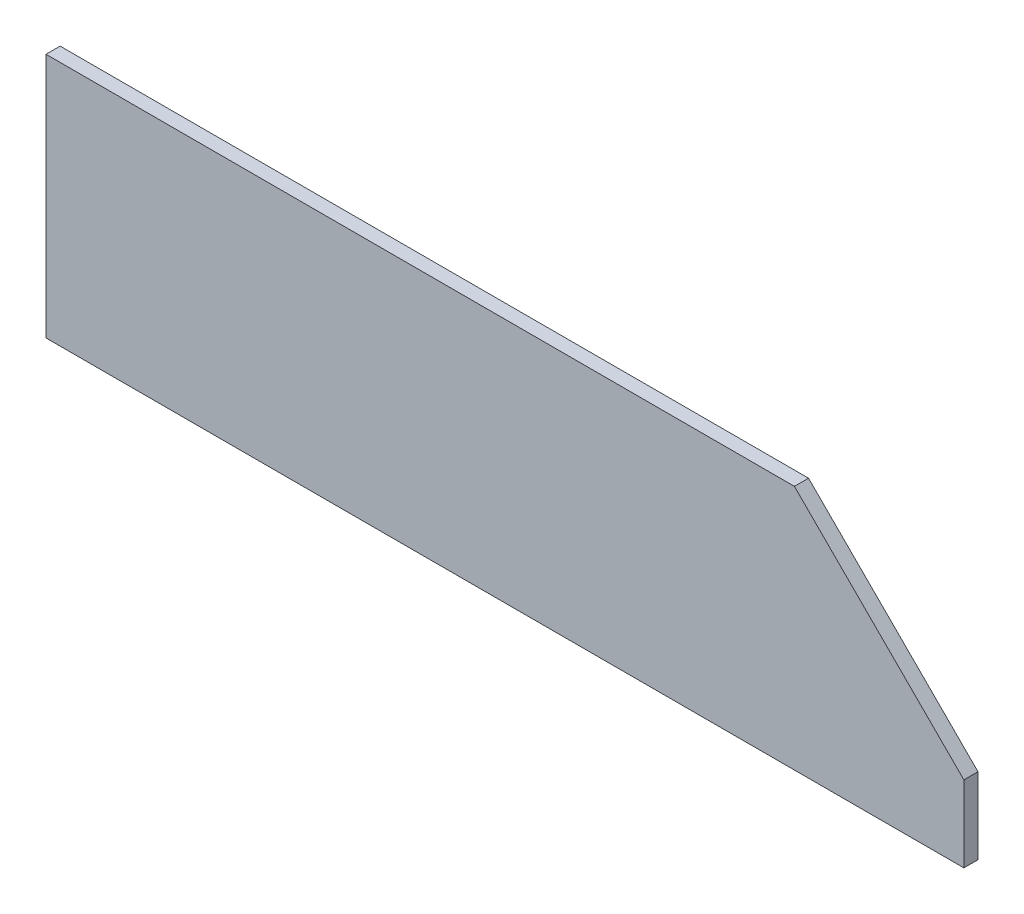
from build123d import *

# Parameters (mm, degrees)
SKETCH1_W           = 325
SKETCH1_H           = 5
BOSS_EXTRUDE1_DEPTH = 87
CHAMFER1_SIZE       = 60


with BuildPart() as part:
    # Sketch1 → Boss-Extrude1 (new body)
    with BuildSketch(Plane(origin=(0, 0, 0), x_dir=(1, 0, 0), z_dir=(0, 1, 0))):
        Rectangle(SKETCH1_W, SKETCH1_H)
    extrude(amount=BOSS_EXTRUDE1_DEPTH)

    # Chamfer1
    chamfer1_edges = [part.edges().sort_by_distance(p)[0] for p in [
        (162.5, 87, 0),
    ]]
    chamfer(chamfer1_edges, length=CHAMFER1_SIZE)


solid = part.part
